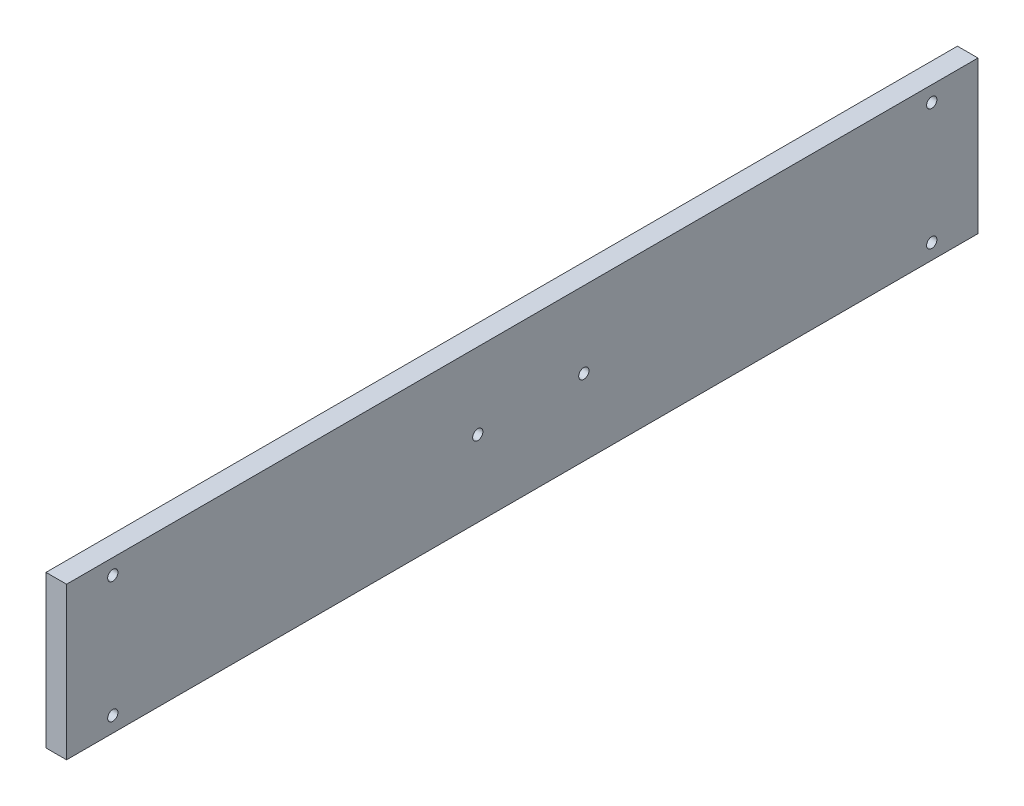
from build123d import *

# Parameters (mm, degrees)
SKETCH1_W           = 150
SKETCH1_H           = 74
BOSS_EXTRUDE1_DEPTH = 10
SKETCH2_W           = 10
SKETCH2_H           = 74
BOSS_EXTRUDE2_DEPTH = 283.402218
SKETCH3_W           = 10
SKETCH3_H           = 74
BOSS_EXTRUDE3_DEPTH = 10
SKETCH4_R           = 2.5
CUT_EXTRUDE1_DEPTH  = 10
SKETCH11_R          = 2.5
CUT_EXTRUDE2_DEPTH  = 10


with BuildPart() as part:
    # Sketch1 → Boss-Extrude1 (new body)
    with BuildSketch(Plane(origin=(0, 0, 0), x_dir=(0, 0, -1), z_dir=(1, 0, 0))):
        Rectangle(SKETCH1_W, SKETCH1_H)
    extrude(amount=BOSS_EXTRUDE1_DEPTH)

    # Sketch2 → Boss-Extrude2 (add)
    with BuildSketch(Plane(origin=(0, 0, -75), x_dir=(-1, 0, 0), z_dir=(0, 0, -1))):
        with Locations((-5, 0)):
            Rectangle(SKETCH2_W, SKETCH2_H)
    extrude(amount=BOSS_EXTRUDE2_DEPTH)

    # Sketch3 → Boss-Extrude3 (add)
    with BuildSketch(Plane(origin=(0, 0, -358.402218), x_dir=(-1, 0, 0), z_dir=(0, 0, -1))):
        with Locations((-5, 0)):
            Rectangle(SKETCH3_W, SKETCH3_H)
    extrude(amount=BOSS_EXTRUDE3_DEPTH)

    # Sketch4 → Cut-Extrude1 (cut)
    with BuildSketch(Plane.ZY):
        with Locations((52.5, -29.5)):
            Circle(SKETCH4_R)
        with Locations((52.5, 29.5)):
            Circle(SKETCH4_R)
        with Locations((-345.902218, 29.5)):
            Circle(SKETCH4_R)
        with Locations((-345.902218, -29.5)):
            Circle(SKETCH4_R)
    extrude(amount=-CUT_EXTRUDE1_DEPTH, mode=Mode.SUBTRACT)

    # Sketch11 → Cut-Extrude2 (cut)
    with BuildSketch(Plane.ZY):
        with Locations((-125.052041, 0)):
            Circle(SKETCH11_R)
        with Locations((-176.647959, 0)):
            Circle(SKETCH11_R)
    extrude(amount=-CUT_EXTRUDE2_DEPTH, mode=Mode.SUBTRACT)


solid = part.part
